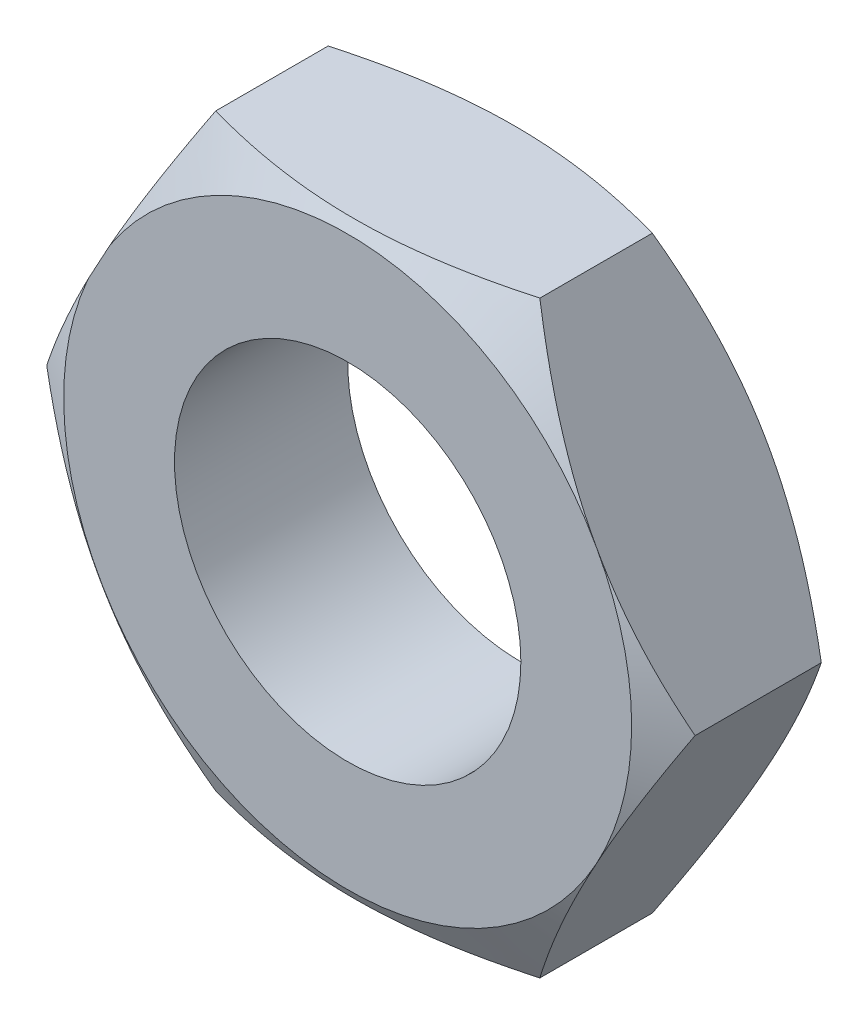
from build123d import *

# Parameters (mm, degrees)
BOSS_EXTRUDE1_DEPTH = 5
SKETCH2_OUTSIDE_W   = 60.516
SKETCH2_OUTSIDE_H   = 58.796
SKETCH2_OUTSIDE_R   = 8.199202844
CUT_EXTRUDE1_DEPTH  = 10
CUT_EXTRUDE1_TAPER  = 60
SKETCH3_OUTSIDE_W   = 29.34
SKETCH3_OUTSIDE_H   = 27.62
SKETCH3_OUTSIDE_R   = 8.172152793
CUT_EXTRUDE2_DEPTH  = 1
CUT_EXTRUDE2_TAPER  = 60
SKETCH4_R           = 5
CUT_EXTRUDE3_DEPTH  = 8


with BuildPart() as part:
    # Sketch1 → Boss-Extrude1 (new body)
    with BuildSketch(Plane.XY):
        Polygon((9.359699903, 0), (4.68, 8.5), (-4.68, 8.5), (-9.36, -0.105997779), (-4.68, -8.5), (4.68, -8.5), align=None)
    extrude(amount=BOSS_EXTRUDE1_DEPTH)

    # Sketch2 outside → Cut-Extrude1 (cut)
    with BuildSketch(Plane.XY.offset(5)):
        Rectangle(SKETCH2_OUTSIDE_W, SKETCH2_OUTSIDE_H)
        Circle(SKETCH2_OUTSIDE_R, mode=Mode.SUBTRACT)
    extrude(amount=-CUT_EXTRUDE1_DEPTH, taper=CUT_EXTRUDE1_TAPER, mode=Mode.SUBTRACT)

    # Sketch3 outside → Cut-Extrude2 (cut)
    with BuildSketch(Plane(origin=(0, 0, 0), x_dir=(-1, 0, 0), z_dir=(0, 0, -1))):
        Rectangle(SKETCH3_OUTSIDE_W, SKETCH3_OUTSIDE_H)
        Circle(SKETCH3_OUTSIDE_R, mode=Mode.SUBTRACT)
    extrude(amount=-CUT_EXTRUDE2_DEPTH, taper=CUT_EXTRUDE2_TAPER, mode=Mode.SUBTRACT)

    # Sketch4 → Cut-Extrude3 (cut)
    with BuildSketch(Plane.XY.offset(5)):
        Circle(SKETCH4_R)
    extrude(amount=-CUT_EXTRUDE3_DEPTH, mode=Mode.SUBTRACT)


solid = part.part
